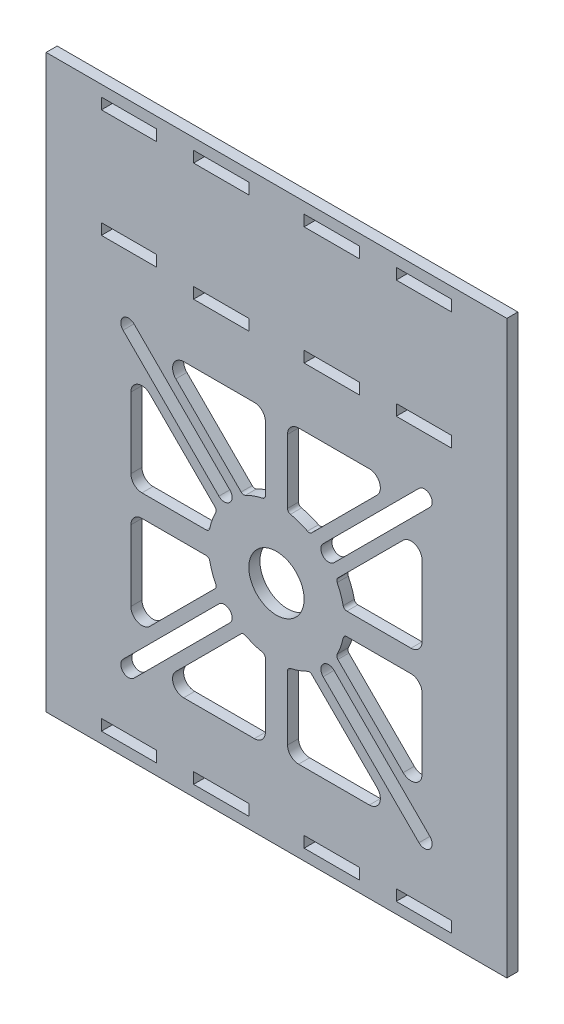
from build123d import *

# Parameters (mm, degrees)
SKETCH1_W           = 125
SKETCH1_H           = 155
SKETCH1_R           = 7.5
SKETCH1_W_2         = 15
SKETCH1_H_2         = 3
BOSS_EXTRUDE1_DEPTH = 3


with BuildPart() as part:
    # Sketch1 → Boss-Extrude1 (new body)
    with BuildSketch(Plane.XY):
        Rectangle(SKETCH1_W, SKETCH1_H)
        with Locations((0, -16)):
            Circle(SKETCH1_R, mode=Mode.SUBTRACT)
        with Locations((15, 73)):
            Rectangle(SKETCH1_W_2, SKETCH1_H_2, mode=Mode.SUBTRACT)
        with Locations((-40, 73)):
            Rectangle(SKETCH1_W_2, SKETCH1_H_2, mode=Mode.SUBTRACT)
        with Locations((-15, 73)):
            Rectangle(SKETCH1_W_2, SKETCH1_H_2, mode=Mode.SUBTRACT)
        with Locations((40, 73)):
            Rectangle(SKETCH1_W_2, SKETCH1_H_2, mode=Mode.SUBTRACT)
        with Locations((40, -73)):
            Rectangle(SKETCH1_W_2, SKETCH1_H_2, mode=Mode.SUBTRACT)
        with Locations((15, -73)):
            Rectangle(SKETCH1_W_2, SKETCH1_H_2, mode=Mode.SUBTRACT)
        with Locations((-15, -73)):
            Rectangle(SKETCH1_W_2, SKETCH1_H_2, mode=Mode.SUBTRACT)
        with Locations((-40, -73)):
            Rectangle(SKETCH1_W_2, SKETCH1_H_2, mode=Mode.SUBTRACT)
        with Locations((15, 41)):
            Rectangle(SKETCH1_W_2, SKETCH1_H_2, mode=Mode.SUBTRACT)
        with Locations((-15, 41)):
            Rectangle(SKETCH1_W_2, SKETCH1_H_2, mode=Mode.SUBTRACT)
        with BuildLine():
            Line((39.5, -10), (39.5, 9.186291501))
            ThreePointArc((39.5, 9.186291501), (37.648050297, 11.957930099), (34.378679656, 11.307611845))
            Line((34.378679656, 11.307611845), (16.655175669, -6.415892143))
            ThreePointArc((16.655175669, -6.415892143), (16.374485428, -6.967252196), (16.471908992, -7.578229748))
            ThreePointArc((16.471908992, -7.578229748), (17.443347183, -9.83723771), (18.106599572, -12.205128205))
            ThreePointArc((18.106599572, -12.205128205), (18.454909512, -12.776250026), (19.085334684, -13))
            Line((19.085334684, -13), (36.5, -13))
            ThreePointArc((36.5, -13), (38.621320344, -12.121320344), (39.5, -10))
        make_face(mode=Mode.SUBTRACT)
        with BuildLine():
            Line((3, -35.085334684), (3, -52.5))
            ThreePointArc((3, -52.5), (3.878679656, -54.621320344), (6, -55.5))
            Line((6, -55.5), (25.186291501, -55.5))
            ThreePointArc((25.186291501, -55.5), (27.957930099, -53.648050297), (27.307611845, -50.378679656))
            Line((27.307611845, -50.378679656), (9.584107857, -32.655175669))
            ThreePointArc((9.584107857, -32.655175669), (9.032747804, -32.374485428), (8.421770252, -32.471908992))
            ThreePointArc((8.421770252, -32.471908992), (6.16276229, -33.443347183), (3.794871795, -34.106599572))
            ThreePointArc((3.794871795, -34.106599572), (3.223749974, -34.454909512), (3, -35.085334684))
        make_face(mode=Mode.SUBTRACT)
        with BuildLine():
            Line((16.655175669, -25.584107857), (34.378679656, -43.307611845))
            ThreePointArc((34.378679656, -43.307611845), (37.648050297, -43.957930099), (39.5, -41.186291501))
            Line((39.5, -41.186291501), (39.5, -22))
            ThreePointArc((39.5, -22), (38.621320344, -19.878679656), (36.5, -19))
            Line((36.5, -19), (19.085334684, -19))
            ThreePointArc((19.085334684, -19), (18.454909512, -19.223749974), (18.106599572, -19.794871795))
            ThreePointArc((18.106599572, -19.794871795), (17.443347183, -22.16276229), (16.471908992, -24.421770252))
            ThreePointArc((16.471908992, -24.421770252), (16.374485428, -25.032747804), (16.655175669, -25.584107857))
        make_face(mode=Mode.SUBTRACT)
        with BuildLine():
            Line((6, 23.5), (25.186291501, 23.5))
            ThreePointArc((25.186291501, 23.5), (27.957930099, 21.648050297), (27.307611845, 18.378679656))
            Line((27.307611845, 18.378679656), (9.584107857, 0.655175669))
            ThreePointArc((9.584107857, 0.655175669), (9.032747804, 0.374485428), (8.421770252, 0.471908992))
            ThreePointArc((8.421770252, 0.471908992), (6.16276229, 1.443347183), (3.794871795, 2.106599572))
            ThreePointArc((3.794871795, 2.106599572), (3.223749974, 2.454909512), (3, 3.085334684))
            Line((3, 3.085334684), (3, 20.5))
            ThreePointArc((3, 20.5), (3.878679656, 22.621320344), (6, 23.5))
        make_face(mode=Mode.SUBTRACT)
        with BuildLine():
            Line((-3, 3.085334684), (-3, 20.5))
            ThreePointArc((-3, 20.5), (-3.878679656, 22.621320344), (-6, 23.5))
            Line((-6, 23.5), (-25.186291501, 23.5))
            ThreePointArc((-25.186291501, 23.5), (-27.957930099, 21.648050297), (-27.307611845, 18.378679656))
            Line((-27.307611845, 18.378679656), (-9.584107857, 0.655175669))
            ThreePointArc((-9.584107857, 0.655175669), (-9.032747804, 0.374485428), (-8.421770252, 0.471908992))
            ThreePointArc((-8.421770252, 0.471908992), (-6.16276229, 1.443347183), (-3.794871795, 2.106599572))
            ThreePointArc((-3.794871795, 2.106599572), (-3.223749974, 2.454909512), (-3, 3.085334684))
        make_face(mode=Mode.SUBTRACT)
        with BuildLine():
            Line((-39.5, -10), (-39.5, 9.186291501))
            ThreePointArc((-39.5, 9.186291501), (-37.648050297, 11.957930099), (-34.378679656, 11.307611845))
            Line((-34.378679656, 11.307611845), (-16.655175669, -6.415892143))
            ThreePointArc((-16.655175669, -6.415892143), (-16.374485428, -6.967252196), (-16.471908992, -7.578229748))
            ThreePointArc((-16.471908992, -7.578229748), (-17.443347183, -9.83723771), (-18.106599572, -12.205128205))
            ThreePointArc((-18.106599572, -12.205128205), (-18.454909512, -12.776250026), (-19.085334684, -13))
            Line((-19.085334684, -13), (-36.5, -13))
            ThreePointArc((-36.5, -13), (-38.621320344, -12.121320344), (-39.5, -10))
        make_face(mode=Mode.SUBTRACT)
        with BuildLine():
            Line((-19.085334684, -19), (-36.5, -19))
            ThreePointArc((-36.5, -19), (-38.621320344, -19.878679656), (-39.5, -22))
            Line((-39.5, -22), (-39.5, -41.186291501))
            ThreePointArc((-39.5, -41.186291501), (-37.648050297, -43.957930099), (-34.378679656, -43.307611845))
            Line((-34.378679656, -43.307611845), (-16.655175669, -25.584107857))
            ThreePointArc((-16.655175669, -25.584107857), (-16.374485428, -25.032747804), (-16.471908992, -24.421770252))
            ThreePointArc((-16.471908992, -24.421770252), (-17.443347183, -22.16276229), (-18.106599572, -19.794871795))
            ThreePointArc((-18.106599572, -19.794871795), (-18.454909512, -19.223749974), (-19.085334684, -19))
        make_face(mode=Mode.SUBTRACT)
        with BuildLine():
            Line((-3, -35.085334684), (-3, -52.5))
            ThreePointArc((-3, -52.5), (-3.878679656, -54.621320344), (-6, -55.5))
            Line((-6, -55.5), (-25.186291501, -55.5))
            ThreePointArc((-25.186291501, -55.5), (-27.957930099, -53.648050297), (-27.307611845, -50.378679656))
            Line((-27.307611845, -50.378679656), (-9.584107857, -32.655175669))
            ThreePointArc((-9.584107857, -32.655175669), (-9.032747804, -32.374485428), (-8.421770252, -32.471908992))
            ThreePointArc((-8.421770252, -32.471908992), (-6.16276229, -33.443347183), (-3.794871795, -34.106599572))
            ThreePointArc((-3.794871795, -34.106599572), (-3.223749974, -34.454909512), (-3, -35.085334684))
        make_face(mode=Mode.SUBTRACT)
        with BuildLine():
            Line((12.657211383, -0.372940136), (38.658474042, 25.628322523))
            ThreePointArc((38.658474042, 25.628322523), (41.628322523, 25.628322523), (41.628322523, 22.658474042))
            Line((41.628322523, 22.658474042), (15.627059864, -3.342788617))
            ThreePointArc((15.627059864, -3.342788617), (12.657211383, -3.342788617), (12.657211383, -0.372940136))
        make_face(mode=Mode.SUBTRACT)
        with BuildLine():
            Line((12.657211383, -31.627059864), (38.658474042, -57.628322523))
            ThreePointArc((38.658474042, -57.628322523), (41.628322523, -57.628322523), (41.628322523, -54.658474042))
            Line((41.628322523, -54.658474042), (15.627059864, -28.657211383))
            ThreePointArc((15.627059864, -28.657211383), (12.657211383, -28.657211383), (12.657211383, -31.627059864))
        make_face(mode=Mode.SUBTRACT)
        with BuildLine():
            Line((-12.657211383, -31.627059864), (-38.658474042, -57.628322523))
            ThreePointArc((-38.658474042, -57.628322523), (-41.628322523, -57.628322523), (-41.628322523, -54.658474042))
            Line((-41.628322523, -54.658474042), (-15.627059864, -28.657211383))
            ThreePointArc((-15.627059864, -28.657211383), (-12.657211383, -28.657211383), (-12.657211383, -31.627059864))
        make_face(mode=Mode.SUBTRACT)
        with BuildLine():
            Line((-12.657211383, -0.372940136), (-38.658474042, 25.628322523))
            ThreePointArc((-38.658474042, 25.628322523), (-41.628322523, 25.628322523), (-41.628322523, 22.658474042))
            Line((-41.628322523, 22.658474042), (-15.627059864, -3.342788617))
            ThreePointArc((-15.627059864, -3.342788617), (-12.657211383, -3.342788617), (-12.657211383, -0.372940136))
        make_face(mode=Mode.SUBTRACT)
        with Locations((40, 41)):
            Rectangle(SKETCH1_W_2, SKETCH1_H_2, mode=Mode.SUBTRACT)
        with Locations((-40, 43.5)):
            Rectangle(SKETCH1_W_2, SKETCH1_H_2, mode=Mode.SUBTRACT)
    extrude(amount=BOSS_EXTRUDE1_DEPTH)


solid = part.part
